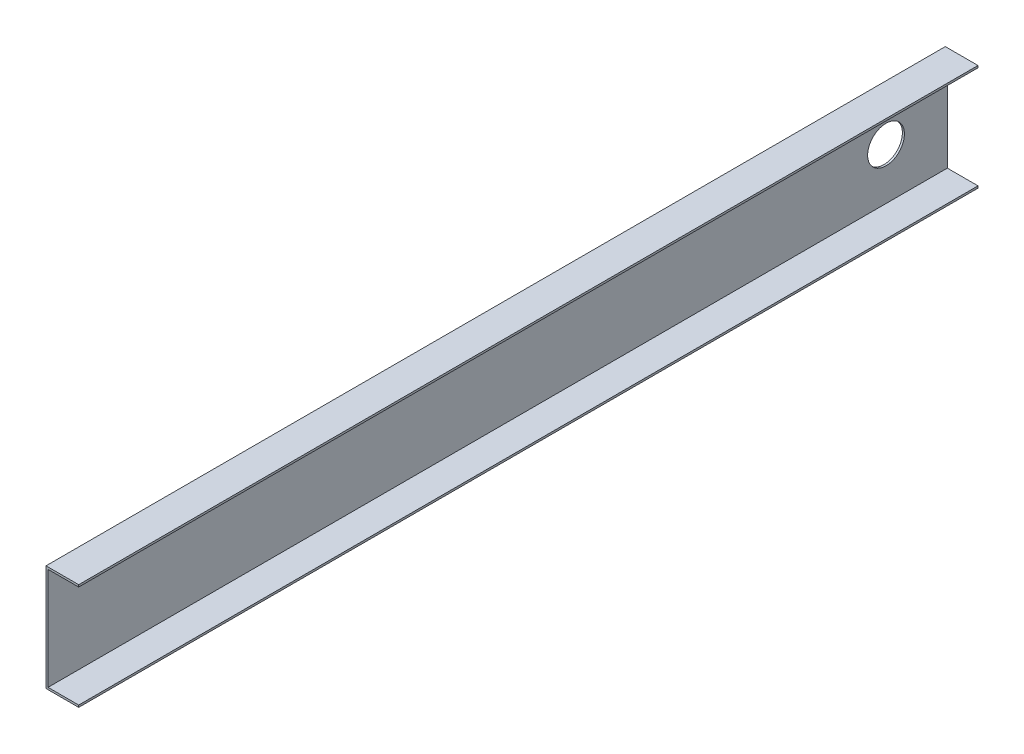
from build123d import *

# Parameters (mm, degrees)
RESSALTO_EXTRUS_O1_DEPTH = 220
ESBO_O2_R                = 4.5
CORTE_EXTRUS_O1_DEPTH    = 10


with BuildPart() as part:
    # Esboço1 → Ressalto-extrusão1 (new body)
    with BuildSketch(Plane.XY):
        Polygon((8, 13), (0, 13), (0, -13), (8, -13), (8, -12.5), (0.5, -12.5), (0.5, 12.5), (8, 12.5), align=None)
    extrude(amount=RESSALTO_EXTRUS_O1_DEPTH)

    # Esboço2 → Corte-extrusão1 (cut)
    with BuildSketch(Plane.ZY):
        with Locations((15, 0)):
            Circle(ESBO_O2_R)
    extrude(amount=-CORTE_EXTRUS_O1_DEPTH, mode=Mode.SUBTRACT)


solid = part.part
